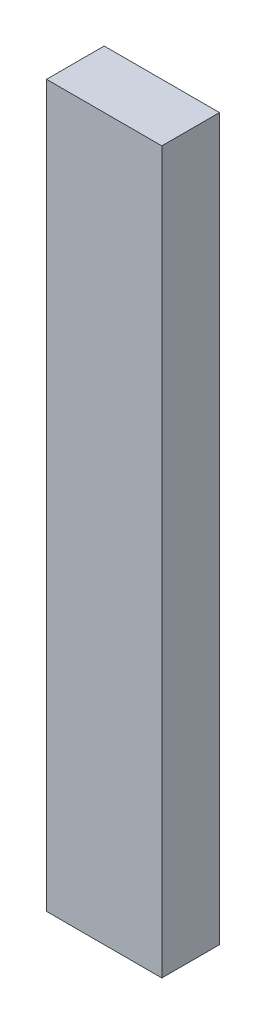
from build123d import *

# Parameters (mm, degrees)
SKETCH1_W           = 50.8
SKETCH1_H           = 317.5
BOSS_EXTRUDE1_DEPTH = 25.4


with BuildPart() as part:
    # Sketch1 → Boss-Extrude1 (new body)
    with BuildSketch(Plane.XY):
        with Locations((25.4, 158.75)):
            Rectangle(SKETCH1_W, SKETCH1_H)
    extrude(amount=BOSS_EXTRUDE1_DEPTH)


solid = part.part
